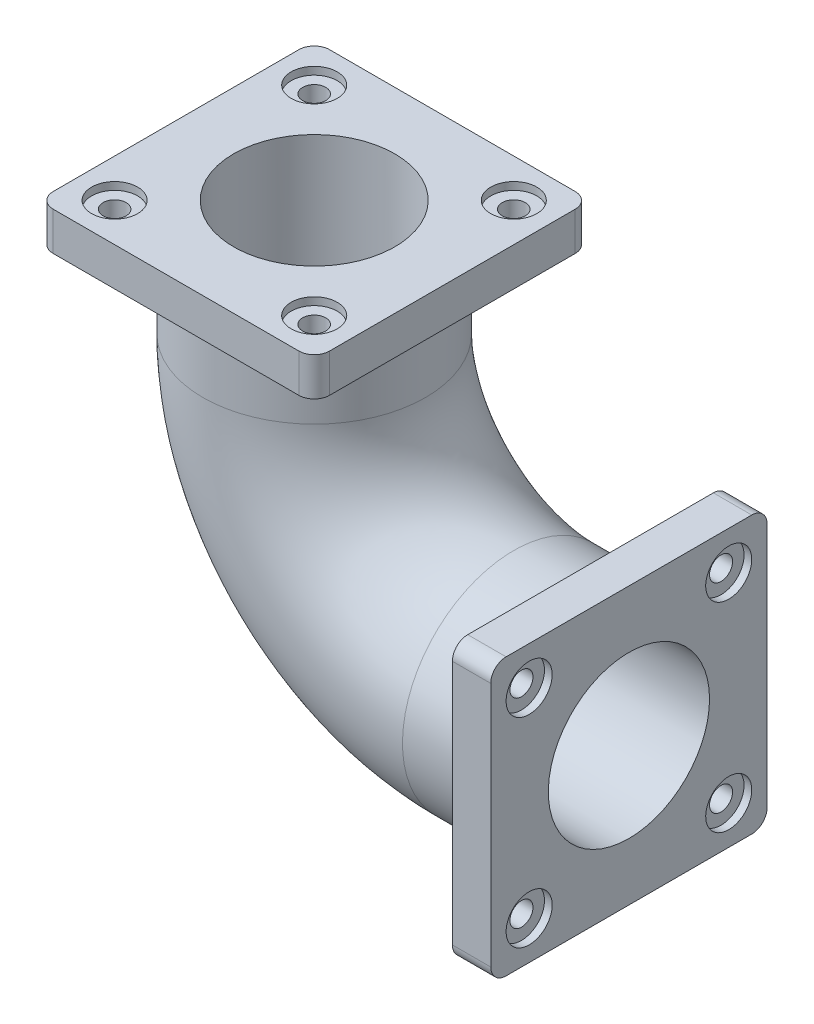
from build123d import *

# Parameters (mm, degrees)
SKETCH2_R           = 145
SKETCH2_R_2         = 105
SKETCH3_W           = 360
SKETCH3_H           = 360
SKETCH3_R           = 145
BOSS_EXTRUDE1_DEPTH = 50
FILLET1_R           = 20
SKETCH4_W           = 360
SKETCH4_H           = 360
SKETCH4_R           = 145
BOSS_EXTRUDE2_DEPTH = 50
FILLET2_R           = 20
SKETCH5_R           = 30
CUT_EXTRUDE1_DEPTH  = 10
SKETCH6_R           = 15
CUT_EXTRUDE2_DEPTH  = 40
CIRPATTERN1_COUNT   = 4
SKETCH7_R           = 30
CUT_EXTRUDE3_DEPTH  = 10
SKETCH8_R           = 15
CUT_EXTRUDE4_DEPTH  = 40
CIRPATTERN2_COUNT   = 4


with BuildPart() as part:
    # Sweep-Thin1: sweep along a path in Sketch1
    with BuildLine(Plane.XY) as sweep_thin1_path:
        Line((0, 0), (-150, 0))
        ThreePointArc((-150, 0), (-333.847763109, 76.152236891), (-410, 260))
        Line((-410, 260), (-410, 410))
    # Sketch2 → Sweep-Thin1 (sweep)
    with BuildSketch(Plane(origin=(0, 0, 0), x_dir=(0, 0, -1), z_dir=(1, 0, 0))):
        Circle(SKETCH2_R)
        Circle(SKETCH2_R_2, mode=Mode.SUBTRACT)
    sweep(path=sweep_thin1_path.line)

    # Sketch3 → Boss-Extrude1 (add)
    with BuildSketch(Plane(origin=(0, 0, 0), x_dir=(0, 0, -1), z_dir=(1, 0, 0))):
        Rectangle(SKETCH3_W, SKETCH3_H)
        Circle(SKETCH3_R, mode=Mode.SUBTRACT)
    extrude(amount=-BOSS_EXTRUDE1_DEPTH)

    # Fillet1
    fillet1_edges = [part.edges().sort_by_distance(p)[0] for p in [
        (-25, 180, -180),
        (-25, -180, -180),
        (-25, -180, 180),
        (-25, 180, 180),
    ]]
    fillet(fillet1_edges, radius=FILLET1_R)

    # Sketch4 → Boss-Extrude2 (add)
    with BuildSketch(Plane(origin=(0, 410, 0), x_dir=(1, 0, 0), z_dir=(0, 1, 0))):
        with Locations((-410, 0)):
            Rectangle(SKETCH4_W, SKETCH4_H)
        with Locations((-410, 0)):
            Circle(SKETCH4_R, mode=Mode.SUBTRACT)
    extrude(amount=-BOSS_EXTRUDE2_DEPTH)

    # Fillet2
    fillet2_edges = [part.edges().sort_by_distance(p)[0] for p in [
        (-590, 385, 180),
        (-590, 385, -180),
        (-230, 385, -180),
        (-230, 385, 180),
    ]]
    fillet(fillet2_edges, radius=FILLET2_R)

    # Sketch5 → Cut-Extrude1 (cut)
    with BuildSketch(Plane(origin=(0, 410, 0), x_dir=(1, 0, 0), z_dir=(0, 1, 0))):
        with Locations((-280, 130)):
            Circle(SKETCH5_R)
    cut_extrude1 = extrude(amount=-CUT_EXTRUDE1_DEPTH, mode=Mode.SUBTRACT)

    # Sketch6 → Cut-Extrude2 (cut)
    with BuildSketch(Plane(origin=(0, 400, 0), x_dir=(1, 0, 0), z_dir=(0, 1, 0))):
        with Locations((-280, 130)):
            Circle(SKETCH6_R)
    cut_extrude2 = extrude(amount=-CUT_EXTRUDE2_DEPTH, mode=Mode.SUBTRACT)

    # CirPattern1: Cut-Extrude1, Cut-Extrude2 ×4 about axis
    cirpattern1_axis = Axis((-410, 0, 0), (0, 1, 0))
    for i in range(1, CIRPATTERN1_COUNT):
        add(cut_extrude1.rotate(cirpattern1_axis, i * 360 / CIRPATTERN1_COUNT), mode=Mode.SUBTRACT)
        add(cut_extrude2.rotate(cirpattern1_axis, i * 360 / CIRPATTERN1_COUNT), mode=Mode.SUBTRACT)

    # Sketch7 → Cut-Extrude3 (cut)
    with BuildSketch(Plane(origin=(0, 0, 0), x_dir=(0, 0, -1), z_dir=(1, 0, 0))):
        with Locations((130, 130)):
            Circle(SKETCH7_R)
    cut_extrude3 = extrude(amount=-CUT_EXTRUDE3_DEPTH, mode=Mode.SUBTRACT)

    # Sketch8 → Cut-Extrude4 (cut)
    with BuildSketch(Plane(origin=(-10, 0, 0), x_dir=(0, 0, -1), z_dir=(1, 0, 0))):
        with Locations((130, 130)):
            Circle(SKETCH8_R)
    cut_extrude4 = extrude(amount=-CUT_EXTRUDE4_DEPTH, mode=Mode.SUBTRACT)

    # CirPattern2: Cut-Extrude3, Cut-Extrude4 ×4 about axis
    cirpattern2_axis = Axis((0, 0, 0), (1, 0, 0))
    for i in range(1, CIRPATTERN2_COUNT):
        add(cut_extrude3.rotate(cirpattern2_axis, i * 360 / CIRPATTERN2_COUNT), mode=Mode.SUBTRACT)
        add(cut_extrude4.rotate(cirpattern2_axis, i * 360 / CIRPATTERN2_COUNT), mode=Mode.SUBTRACT)


solid = part.part
